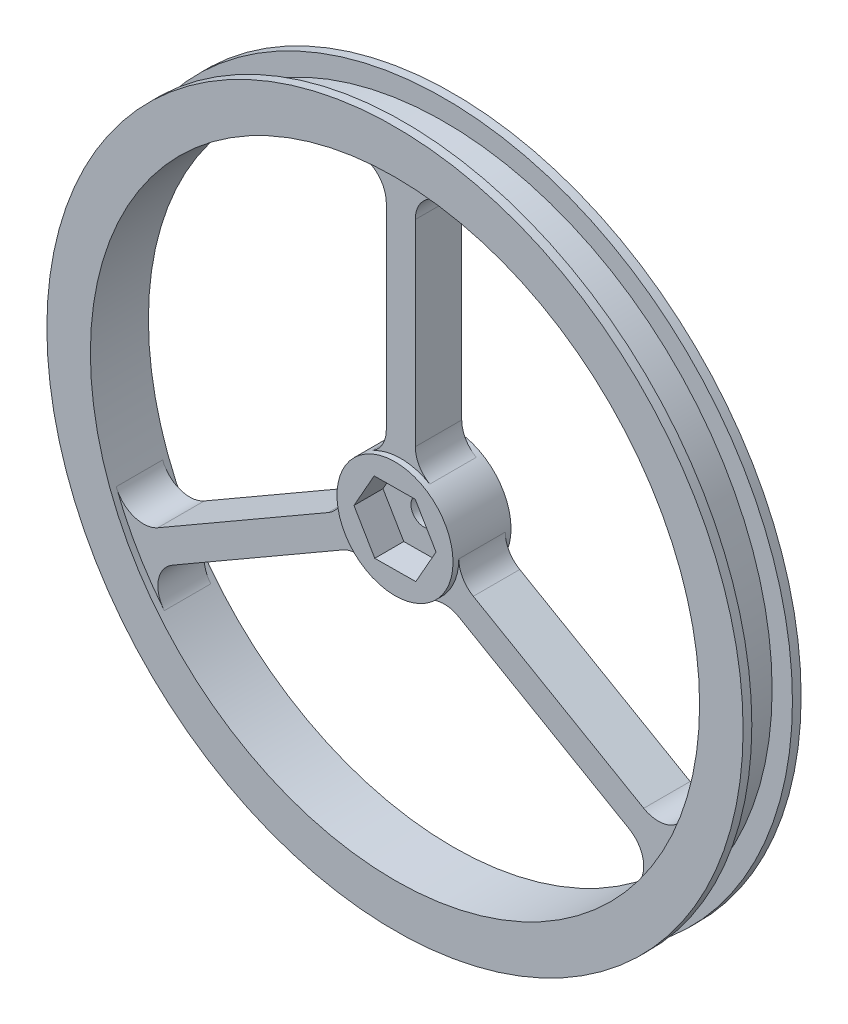
from build123d import *

# Parameters (mm, degrees)
SKETCH1_R           = 30.48
SKETCH1_R_2         = 1.143
BOSS_EXTRUDE1_DEPTH = 5.08
CUT_EXTRUDE1_DEPTH  = 2.54
SKETCH3_W           = 3.556
SKETCH3_H           = 1.778
SKETCH6_R           = 26.67
SKETCH6_R_2         = 5.08
CUT_EXTRUDE2_DEPTH  = 0.508
SKETCH8_R           = 26.67
SKETCH8_R_2         = 5.08
CUT_EXTRUDE3_DEPTH  = 0.508


with BuildPart() as part:
    # Sketch1 → Boss-Extrude1 (new body)
    with BuildSketch(Plane.XY):
        Circle(SKETCH1_R)
        Circle(SKETCH1_R_2, mode=Mode.SUBTRACT)
        with BuildLine():
            Line((-1.27, 23.82731206), (-1.27, 6.599113577))
            ThreePointArc((-1.27, 6.599113577), (-1.610295474, 5.329113577), (-2.54, 4.399409051))
            ThreePointArc((-2.54, 4.399409051), (-4.399409051, 2.54), (-5.08, 0))
            ThreePointArc((-5.08, 0), (-5.420295474, -1.27), (-6.35, -2.199704526))
            Line((-6.35, -2.199704526), (-21.270057548, -10.813803767))
            ThreePointArc((-21.270057548, -10.813803767), (-23.389696909, -11.007781124), (-24.912695184, -9.52084653))
            ThreePointArc((-24.912695184, -9.52084653), (-23.096897519, 13.335), (-4.211052632, 26.335450171))
            ThreePointArc((-4.211052632, 26.335450171), (-2.161830361, 25.759962272), (-1.27, 23.82731206))
        make_face(mode=Mode.SUBTRACT)
        with BuildLine():
            Line((1.27, 23.82731206), (1.27, 6.599113577))
            ThreePointArc((1.27, 6.599113577), (1.610295474, 5.329113577), (2.54, 4.399409051))
            ThreePointArc((2.54, 4.399409051), (4.399409051, 2.54), (5.08, 0))
            ThreePointArc((5.08, 0), (5.420295474, -1.27), (6.35, -2.199704526))
            Line((6.35, -2.199704526), (21.270057548, -10.813803767))
            ThreePointArc((21.270057548, -10.813803767), (23.389696909, -11.007781124), (24.912695184, -9.52084653))
            ThreePointArc((24.912695184, -9.52084653), (23.096897519, 13.335), (4.211052632, 26.335450171))
            ThreePointArc((4.211052632, 26.335450171), (2.161830361, 25.759962272), (1.27, 23.82731206))
        make_face(mode=Mode.SUBTRACT)
        with BuildLine():
            Line((20.000057548, -13.013508293), (5.08, -4.399409051))
            ThreePointArc((5.08, -4.399409051), (3.81, -4.059113577), (2.54, -4.399409051))
            ThreePointArc((2.54, -4.399409051), (0, -5.08), (-2.54, -4.399409051))
            ThreePointArc((-2.54, -4.399409051), (-3.81, -4.059113577), (-5.08, -4.399409051))
            Line((-5.08, -4.399409051), (-20.000057548, -13.013508293))
            ThreePointArc((-20.000057548, -13.013508293), (-21.227866547, -14.752181148), (-20.701642553, -16.814603641))
            ThreePointArc((-20.701642553, -16.814603641), (0, -26.67), (20.701642553, -16.814603641))
            ThreePointArc((20.701642553, -16.814603641), (21.227866547, -14.752181148), (20.000057548, -13.013508293))
        make_face(mode=Mode.SUBTRACT)
    extrude(amount=BOSS_EXTRUDE1_DEPTH)

    # Sketch2 → Cut-Extrude1 (cut)
    with BuildSketch(Plane.XY.offset(5.08)):
        Polygon((1.770622484, 3.126255324), (-1.822105287, 3.096531714), (-3.592727772, -0.02972361), (-1.770622484, -3.126255324), (1.822105287, -3.096531714), (3.592727772, 0.02972361), align=None)
    extrude(amount=-CUT_EXTRUDE1_DEPTH, mode=Mode.SUBTRACT)

    # Sketch3 → Cut-Revolve1 (revolve, cut)
    with BuildSketch(Plane(origin=(0, 0, 0), x_dir=(0, 0, -1), z_dir=(1, 0, 0))):
        with Locations((-2.54, 29.591)):
            Rectangle(SKETCH3_W, SKETCH3_H)
    revolve(axis=Axis((0, 0, 7.917922269), (0, 0, -1)), mode=Mode.SUBTRACT)

    # Sketch6 → Cut-Extrude2 (cut)
    with BuildSketch(Plane.XY):
        Circle(SKETCH6_R)
        Circle(SKETCH6_R_2, mode=Mode.SUBTRACT)
    extrude(amount=CUT_EXTRUDE2_DEPTH, mode=Mode.SUBTRACT)

    # Sketch8 → Cut-Extrude3 (cut)
    with BuildSketch(Plane.XY.offset(5.08)):
        Circle(SKETCH8_R)
        Circle(SKETCH8_R_2, mode=Mode.SUBTRACT)
    extrude(amount=-CUT_EXTRUDE3_DEPTH, mode=Mode.SUBTRACT)


solid = part.part
